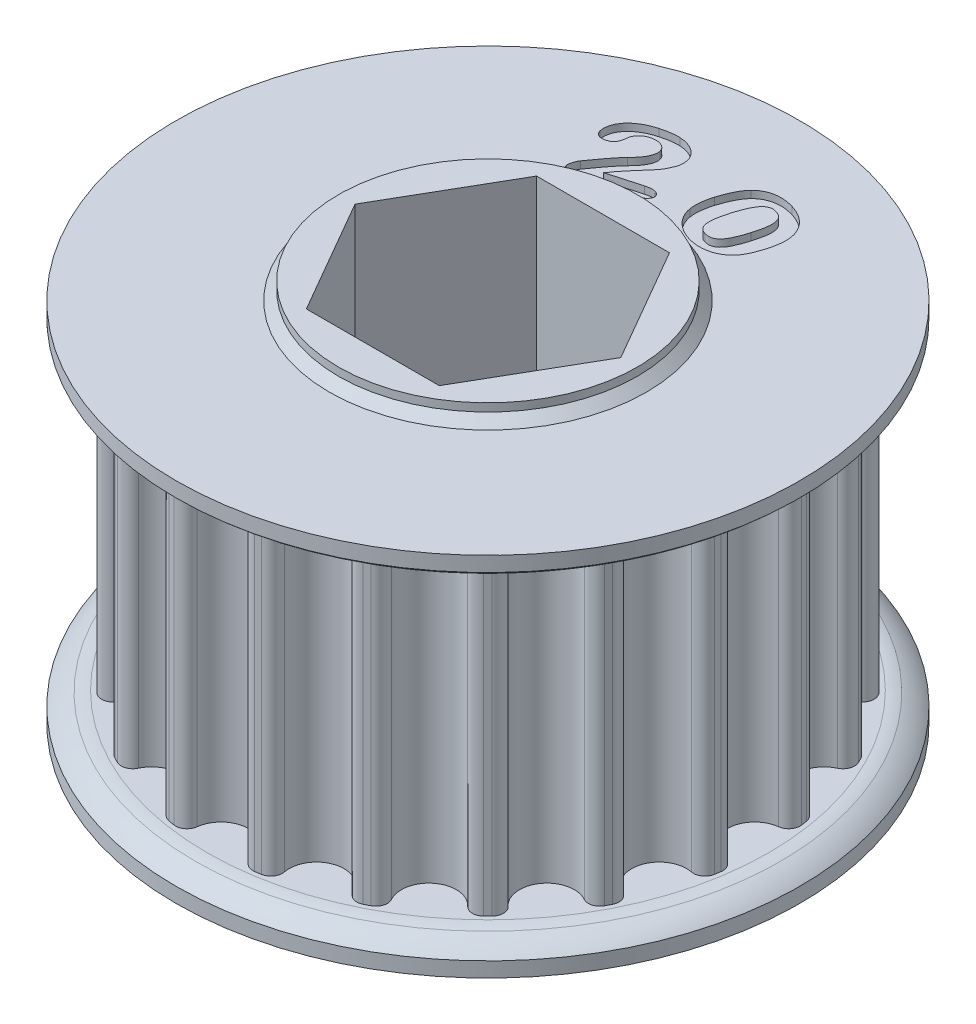
from build123d import *

# Parameters (mm, degrees)
SKETCH1_R               = 15.34399401
TOOTHOD_DEPTH           = 8.5725
TOOTHPROFILE_DEPTH      = 18.145
TOOTHPATTERN_COUNT      = 20
SKETCH6_W               = 8.2931
SKETCH6_H               = 0.9525
BORE_DEPTH              = 11.16
BORE_DEPTH_BACK         = 12.1125
LARGE_TOOTH_COUNT_DEPTH = 0.4
CHAMFER1_SIZE           = 0.508


with BuildPart() as part:
    # Sketch1 → ToothOD (new body, symmetric)
    with BuildSketch(Plane(origin=(0, 0, 0), x_dir=(1, 0, 0), z_dir=(0, 1, 0))):
        Circle(SKETCH1_R)
    extrude(amount=TOOTHOD_DEPTH, both=True)

    # Sketch2 → ToothProfile (cut, through all)
    with BuildSketch(Plane(origin=(0, 8.5725, 0), x_dir=(1, 0, 0), z_dir=(0, 1, 0))):
        with BuildLine():
            ThreePointArc((-1.514151189, 14.627414336), (0, 13.28399401), (1.514151189, 14.627414336))
            ThreePointArc((1.514151189, 14.627414336), (1.759047929, 15.056333772), (2.237219512, 15.180019797))
            ThreePointArc((2.237219512, 15.180019797), (0, 15.34399401), (-2.237219512, 15.180019797))
            ThreePointArc((-2.237219512, 15.180019797), (-1.759047929, 15.056333772), (-1.514151189, 14.627414336))
        make_face()
    toothprofile = extrude(amount=-TOOTHPROFILE_DEPTH, mode=Mode.SUBTRACT)

    # ToothPattern: ToothProfile ×20 about axis
    toothpattern_axis = Axis((0, 0, 0), (0, 1, 0))
    for i in range(1, TOOTHPATTERN_COUNT):
        add(toothprofile.rotate(toothpattern_axis, i * 360 / TOOTHPATTERN_COUNT), mode=Mode.SUBTRACT)

    # Sketch4 → Flange (revolve)
    with BuildSketch(Plane.XY):
        with BuildLine():
            Line((0, -8.5725), (15.59799401, -8.5725))
            ThreePointArc((15.59799401, -8.5725), (15.92375, -8.598122571), (16.243566338, -8.665137424))
            ThreePointArc((16.243566338, -8.665137424), (16.811294915, -8.946697125), (17.31249401, -9.3345))
            Line((17.31249401, -9.3345), (17.31249401, -10.16))
            Line((17.31249401, -10.16), (0, -10.16))
            Line((0, -10.16), (0, -8.5725))
        make_face()
        with BuildLine():
            Line((17.31249401, 10.16), (17.31249401, 9.3345))
            ThreePointArc((17.31249401, 9.3345), (16.811294915, 8.946697125), (16.243566338, 8.665137424))
            ThreePointArc((16.243566338, 8.665137424), (15.92375, 8.598122571), (15.59799401, 8.5725))
            Line((15.59799401, 8.5725), (0, 8.5725))
            Line((0, 8.5725), (0, 10.16))
            Line((0, 10.16), (17.31249401, 10.16))
        make_face()
    revolve(axis=Axis((0, 12.09802, 0), (0, -1, 0)))

    # Sketch6 → TopBearingBoss (revolve)
    with BuildSketch(Plane.XY):
        with Locations((4.14655, 10.63625)):
            Rectangle(SKETCH6_W, SKETCH6_H)
    revolve(axis=Axis((0, 12.09802, 0), (0, -1, 0)))

    # Sketch7 → Bore (cut, two sides)
    with BuildSketch(Plane.XZ) as bore_sk:
        Polygon((3.688171255, 6.3881), (-3.688171255, 6.3881), (-7.376342509, 0), (-3.688171255, -6.3881), (3.688171255, -6.3881), (7.376342509, 0), align=None)
    extrude(amount=BORE_DEPTH, mode=Mode.SUBTRACT)
    extrude(bore_sk.sketch, amount=-BORE_DEPTH_BACK, mode=Mode.SUBTRACT)

    # Sketch9 → Large Tooth Count (cut)
    with BuildSketch(Plane(origin=(0, 10.16, 0), x_dir=(1, 0, 0), z_dir=(0, 1, 0))):
        with BuildLine():
            Line((-2.954146893, 9.361462675), (-1.175353143, 9.862418144))
            add(Edge.make_bspline(
                [(-1.175353143, 9.862418144), (-1.123805554, 9.875802418), (-1.026048459, 9.901184938), (-0.883304523, 9.919166454), (-0.754108312, 9.920384436), (-0.63935479, 9.903206029), (-0.541555305, 9.870084112), (-0.462297286, 9.823371078), (-0.402653568, 9.761037925), (-0.383751751, 9.709454292), (-0.374360174, 9.683824394)],
                knots=[0, 0, 0, 0, 0.000159632, 0.000302733, 0.000430427, 0.000546114, 0.000649193, 0.000738172, 0.000820345, 0.000901492, 0.000901492, 0.000901492, 0.000901492], degree=3))
            add(Edge.make_bspline(
                [(-0.374360174, 9.683824394), (-0.369719108, 9.660087819), (-0.360266106, 9.611740771), (-0.371972129, 9.535402151), (-0.403229262, 9.458544917), (-0.453267189, 9.380882786), (-0.526096867, 9.307089619), (-0.62160342, 9.241903313), (-0.739824812, 9.186663473), (-0.827592685, 9.159151), (-0.874422674, 9.144471269)],
                knots=[0, 0, 0, 0, 7.211e-05, 0.000146874, 0.000227464, 0.000319855, 0.000422154, 0.000536349, 0.000664961, 0.000812085, 0.000812085, 0.000812085, 0.000812085], degree=3))
            Line((-0.874422674, 9.144471269), (-3.564937518, 8.387233769))
            add(Edge.make_bspline(
                [(-3.564937518, 8.387233769), (-3.61171521, 8.37543609), (-3.700837127, 8.352958886), (-3.832442975, 8.342282282), (-3.953746135, 8.349940914), (-4.062486177, 8.379695319), (-4.157127763, 8.424314562), (-4.233382296, 8.48426447), (-4.291165156, 8.557997927), (-4.311755017, 8.615372811), (-4.322175018, 8.644408769)],
                knots=[0, 0, 0, 0, 0.000144509, 0.000275322, 0.000394422, 0.00050728, 0.000611516, 0.000706209, 0.000796044, 0.00088809, 0.00088809, 0.00088809, 0.00088809], degree=3))
            add(Edge.make_bspline(
                [(-4.322175018, 8.644408769), (-4.326580812, 8.665164293), (-4.336073853, 8.709885638), (-4.332624611, 8.784411615), (-4.322455052, 8.869128107), (-4.299543845, 8.961161902), (-4.27034487, 9.054523865), (-4.235617728, 9.143365747), (-4.1961476, 9.224365129), (-4.163762464, 9.272780303), (-4.148046112, 9.296275956)],
                knots=[0, 0, 0, 0, 6.342e-05, 0.000136649, 0.000222155, 0.000319406, 0.000420513, 0.000515529, 0.000605383, 0.000690102, 0.000690102, 0.000690102, 0.000690102], degree=3))
            add(Edge.make_bspline(
                [(-4.148046112, 9.296275956), (-4.087211058, 9.382429832), (-3.969092279, 9.549708234), (-3.794337723, 9.790740454), (-3.627134069, 10.014150132), (-3.493100044, 10.188605296), (-3.391151145, 10.317214682), (-3.321382624, 10.403735091), (-3.257675155, 10.482773388), (-3.197071967, 10.55186435), (-3.144281079, 10.614722485), (-3.095438484, 10.668632161), (-3.052483765, 10.714698958), (-3.024770261, 10.742069301), (-3.012189862, 10.754493925)],
                knots=[0, 0, 0, 0, 0.000316401, 0.000614331, 0.000893117, 0.001153528, 0.0012743, 0.001385449, 0.001486981, 0.0015788, 0.001661128, 0.00173321, 0.001797012, 0.001850052, 0.001850052, 0.001850052, 0.001850052], degree=3))
            add(Edge.make_bspline(
                [(-3.012189862, 10.754493925), (-2.97279762, 10.794299168), (-2.896763622, 10.871130331), (-2.792806568, 10.988869332), (-2.701039663, 11.102694717), (-2.620574498, 11.212717556), (-2.553383732, 11.320286413), (-2.497592916, 11.424476859), (-2.454002898, 11.526306534), (-2.422746917, 11.625053273), (-2.402709489, 11.71988848), (-2.394004008, 11.810101015), (-2.397937406, 11.895345873), (-2.409888983, 11.949103964), (-2.415686737, 11.975182206)],
                knots=[0, 0, 0, 0, 0.000167978, 0.000324227, 0.000470938, 0.00060651, 0.000732874, 0.000851114, 0.000960746, 0.001064676, 0.001161348, 0.001251006, 0.001335955, 0.001415989, 0.001415989, 0.001415989, 0.001415989], degree=3))
            add(Edge.make_bspline(
                [(-2.415686737, 11.975182206), (-2.42429087, 12.001758675), (-2.441249197, 12.0541396), (-2.482578582, 12.125664714), (-2.535327991, 12.18909487), (-2.598872825, 12.244238856), (-2.671873029, 12.2906639), (-2.752660218, 12.328719573), (-2.842148698, 12.355153399), (-2.938047159, 12.37159083), (-3.038305704, 12.378979246), (-3.141121707, 12.374657925), (-3.245814936, 12.36229657), (-3.314774119, 12.344214881), (-3.349732049, 12.335048613)],
                knots=[0, 0, 0, 0, 8.3615e-05, 0.000164802, 0.000245979, 0.00033015, 0.000416103, 0.00050479, 0.000597164, 0.000695086, 0.000796244, 0.000898105, 0.001003437, 0.001111733, 0.001111733, 0.001111733, 0.001111733], degree=3))
            add(Edge.make_bspline(
                [(-3.349732049, 12.335048613), (-3.382418939, 12.324700344), (-3.446620887, 12.304374794), (-3.537125411, 12.263067652), (-3.620087769, 12.213267396), (-3.696565155, 12.156329349), (-3.765107736, 12.089722279), (-3.824340499, 12.013694183), (-3.879435722, 11.931578737), (-3.907718253, 11.87113381), (-3.922125018, 11.840343925)],
                knots=[0, 0, 0, 0, 0.000102788, 0.000201892, 0.000297606, 0.000392618, 0.00048734, 0.000583288, 0.000681368, 0.000783202, 0.000783202, 0.000783202, 0.000783202], degree=3))
            add(Edge.make_bspline(
                [(-3.922125018, 11.840343925), (-3.924346544, 11.832933466), (-3.931168204, 11.810178107), (-3.937056605, 11.762522536), (-3.950091222, 11.690823835), (-3.961933852, 11.598900745), (-3.979992527, 11.497578612), (-4.007626887, 11.398655278), (-4.042740729, 11.30637416), (-4.085519388, 11.220216479), (-4.144929258, 11.141703059), (-4.227777014, 11.077150199), (-4.330942518, 11.022005189), (-4.409730011, 10.997774061), (-4.451655487, 10.984879863)],
                knots=[0, 0, 0, 0, 2.3183e-05, 7.1188e-05, 0.000143562, 0.000241939, 0.000349125, 0.000452037, 0.000549551, 0.000645003, 0.000739847, 0.000842071, 0.000957527, 0.001088842, 0.001088842, 0.001088842, 0.001088842], degree=3))
            add(Edge.make_bspline(
                [(-4.451655487, 10.984879863), (-4.484518593, 10.977014405), (-4.548160913, 10.961782248), (-4.644496368, 10.956258535), (-4.73670461, 10.966954595), (-4.82346759, 10.993238394), (-4.901057808, 11.035922061), (-4.965744414, 11.095093645), (-5.016154224, 11.169717324), (-5.035502925, 11.227460955), (-5.045479705, 11.257235331)],
                knots=[0, 0, 0, 0, 0.000101225, 0.000196031, 0.000287742, 0.000378408, 0.000466355, 0.000551051, 0.00063922, 0.00073308, 0.00073308, 0.00073308, 0.00073308], degree=3))
            add(Edge.make_bspline(
                [(-5.045479705, 11.257235331), (-5.05397104, 11.293084372), (-5.071349422, 11.366453082), (-5.077754738, 11.481958813), (-5.072725552, 11.603249079), (-5.051844202, 11.729081667), (-5.016292017, 11.857336166), (-4.964770167, 11.985211731), (-4.897422878, 12.111016582), (-4.814660026, 12.23509846), (-4.715205717, 12.356092866), (-4.597286749, 12.47195975), (-4.46284857, 12.584034957), (-4.31031455, 12.689978389), (-4.14049305, 12.79094259), (-3.950695814, 12.87981994), (-3.743341884, 12.961365981), (-3.596866185, 13.004705712), (-3.521182049, 13.027099394)],
                knots=[0, 0, 0, 0, 0.000110331, 0.000225804, 0.000345582, 0.000474036, 0.000607492, 0.000744128, 0.000886741, 0.001034844, 0.001190912, 0.001355715, 0.001530073, 0.001715374, 0.001912322, 0.002122017, 0.002343396, 0.002580075, 0.002580075, 0.002580075, 0.002580075], degree=3))
            add(Edge.make_bspline(
                [(-3.521182049, 13.027099394), (-3.4736299, 13.03988753), (-3.380335158, 13.064977161), (-3.241544955, 13.097089226), (-3.107026771, 13.124112364), (-2.976265984, 13.14490228), (-2.8495897, 13.158917372), (-2.727192142, 13.168269746), (-2.608850533, 13.171070654), (-2.531470246, 13.16854091), (-2.493375018, 13.167295488)],
                knots=[0, 0, 0, 0, 0.000147715, 0.00028981, 0.000427283, 0.000559265, 0.000686869, 0.000809531, 0.000927433, 0.001041765, 0.001041765, 0.001041765, 0.001041765], degree=3))
            add(Edge.make_bspline(
                [(-2.493375018, 13.167295488), (-2.439709954, 13.16272022), (-2.334541326, 13.153753966), (-2.181332224, 13.127305431), (-2.036981563, 13.087440761), (-1.901006644, 13.037993111), (-1.775042238, 12.977076771), (-1.658865503, 12.907098719), (-1.552797444, 12.827923999), (-1.459758972, 12.738048259), (-1.376703421, 12.643511102), (-1.309975797, 12.541360057), (-1.254518112, 12.43604159), (-1.230849347, 12.361372234), (-1.219108612, 12.324332988)],
                knots=[0, 0, 0, 0, 0.000161536, 0.000316566, 0.000465606, 0.000610256, 0.000750042, 0.000884655, 0.001016637, 0.001146117, 0.001272127, 0.001393235, 0.001511445, 0.001627798, 0.001627798, 0.001627798, 0.001627798], degree=3))
            add(Edge.make_bspline(
                [(-1.219108612, 12.324332988), (-1.211383801, 12.294688493), (-1.195989155, 12.235610479), (-1.183332882, 12.145192252), (-1.176603551, 12.054774787), (-1.178486449, 11.963899215), (-1.188610174, 11.872881101), (-1.205430531, 11.781423706), (-1.230525716, 11.690002431), (-1.274849659, 11.570781829), (-1.33741533, 11.429640428), (-1.41591175, 11.271086939), (-1.50151055, 11.130952631), (-1.579521706, 11.024672795), (-1.647287016, 10.941396881), (-1.706925628, 10.872235184), (-1.772228142, 10.792201909), (-1.847731998, 10.704799598), (-1.931711291, 10.608913676), (-2.022333861, 10.502919779), (-2.123153923, 10.389883416), (-2.227945717, 10.269423426), (-2.334199707, 10.149850826), (-2.432223405, 10.033064938), (-2.522427016, 9.924904713), (-2.603216232, 9.823238211), (-2.675411176, 9.729477266), (-2.73794607, 9.642126083), (-2.79312732, 9.563443557), (-2.824329241, 9.511648282), (-2.838953924, 9.487371269)],
                knots=[0, 0, 0, 0, 9.1833e-05, 0.000183012, 0.000273418, 0.000363625, 0.000455236, 0.000547886, 0.000642338, 0.000739228, 0.000929181, 0.001105295, 0.001269623, 0.001421084, 0.001500437, 0.001591678, 0.001695035, 0.001810293, 0.001938147, 0.002077427, 0.002228635, 0.002392525, 0.002556416, 0.002708483, 0.002849914, 0.002978913, 0.00309804, 0.003204857, 0.003301207, 0.003386208, 0.003386208, 0.003386208, 0.003386208], degree=3))
            add(Edge.make_bspline(
                [(-2.838953924, 9.487371269), (-2.855289837, 9.463900755), (-2.888073876, 9.416798504), (-2.932072354, 9.379949994), (-2.954146893, 9.361462675)],
                knots=[0, 0, 0, 0, 8.5371e-05, 0.000171328, 0.000171328, 0.000171328, 0.000171328], degree=3))
        make_face()
        with BuildLine():
            add(Edge.make_bspline(
                [(5.214409045, 10.150130338), (5.190714867, 10.074880459), (5.1449507, 9.929538937), (5.067123561, 9.722992573), (4.985074358, 9.534662094), (4.897683151, 9.362490125), (4.797990216, 9.204699763), (4.68207819, 9.059315083), (4.548391417, 8.924355594), (4.448207144, 8.844811647), (4.397342639, 8.804426432)],
                knots=[0, 0, 0, 0, 0.000236642, 0.000457062, 0.000661792, 0.000852695, 0.001035762, 0.001220684, 0.001409481, 0.001604192, 0.001604192, 0.001604192, 0.001604192], degree=3))
            add(Edge.make_bspline(
                [(4.397342639, 8.804426432), (4.368452389, 8.783759012), (4.310444351, 8.742261398), (4.218090567, 8.68760354), (4.122567032, 8.636381907), (4.021053968, 8.594804769), (3.917071626, 8.55542857), (3.807864453, 8.524522636), (3.694856927, 8.498897601), (3.578149786, 8.477916033), (3.458784674, 8.465052918), (3.337809148, 8.457659325), (3.215789514, 8.457269131), (3.092816601, 8.466425015), (2.968336345, 8.478893397), (2.842901635, 8.500737733), (2.716334551, 8.529457806), (2.632441476, 8.553128463), (2.589973889, 8.565110807)],
                knots=[0, 0, 0, 0, 0.000106514, 0.000213868, 0.00032171, 0.000431342, 0.000542652, 0.00065513, 0.000771456, 0.000890225, 0.00101063, 0.001131392, 0.001253729, 0.001376329, 0.001501172, 0.001628892, 0.001758002, 0.001890361, 0.001890361, 0.001890361, 0.001890361], degree=3))
            add(Edge.make_bspline(
                [(2.589973889, 8.565110807), (2.543632445, 8.579700214), (2.452042396, 8.608534977), (2.319678008, 8.661606647), (2.193694452, 8.721556974), (2.07328836, 8.787716416), (1.959122861, 8.861323411), (1.84975651, 8.940228266), (1.747631416, 9.027720056), (1.651608943, 9.121077228), (1.562444683, 9.219388851), (1.482907007, 9.322900319), (1.410803045, 9.429205404), (1.348352462, 9.54012966), (1.294619283, 9.655154495), (1.248761777, 9.773672505), (1.213020235, 9.896616587), (1.195786369, 9.980335913), (1.187119983, 10.022435807)],
                knots=[0, 0, 0, 0, 0.00014571, 0.000287984, 0.000427384, 0.000564075, 0.000699818, 0.000834669, 0.000968331, 0.001102838, 0.001236249, 0.001366101, 0.001494145, 0.001621298, 0.001747533, 0.00187473, 0.002002174, 0.00213109, 0.00213109, 0.00213109, 0.00213109], degree=3))
            add(Edge.make_bspline(
                [(1.187119983, 10.022435807), (1.180867164, 10.069996862), (1.168240345, 10.166040708), (1.1601745, 10.312869392), (1.163621366, 10.463459377), (1.174789304, 10.6179706), (1.197160825, 10.776345136), (1.22609065, 10.938288092), (1.264806684, 11.103647427), (1.296751927, 11.213792398), (1.313028577, 11.26991315)],
                knots=[0, 0, 0, 0, 0.000143879, 0.000290546, 0.000440589, 0.000595508, 0.00075501, 0.00092018, 0.001088913, 0.001264195, 0.001264195, 0.001264195, 0.001264195], degree=3))
            add(Edge.make_bspline(
                [(1.313028577, 11.26991315), (1.33538935, 11.341535758), (1.379078841, 11.481475247), (1.452154195, 11.682542865), (1.529127683, 11.87032368), (1.609998022, 12.044290335), (1.6952769, 12.205137541), (1.787378592, 12.350429447), (1.883615047, 12.482465752), (1.954403412, 12.561103972), (1.98900592, 12.599543619)],
                knots=[0, 0, 0, 0, 0.000225072, 0.000439757, 0.00064157, 0.000833726, 0.001015104, 0.001187283, 0.001349449, 0.00150452, 0.00150452, 0.00150452, 0.00150452], degree=3))
            add(Edge.make_bspline(
                [(1.98900592, 12.599543619), (2.018628391, 12.628603845), (2.077103584, 12.685969161), (2.171791495, 12.762895464), (2.270271079, 12.832357217), (2.373785475, 12.892330016), (2.480624357, 12.946184702), (2.592696711, 12.989493011), (2.708793143, 13.025239338), (2.829056329, 13.052964555), (2.952560802, 13.072627552), (3.079412612, 13.083143097), (3.208835866, 13.085694737), (3.341290865, 13.080548732), (3.476299628, 13.065774952), (3.61437117, 13.043471927), (3.75507657, 13.012338384), (3.848891552, 12.985499356), (3.89638717, 12.971911588)],
                knots=[0, 0, 0, 0, 0.000124431, 0.000245628, 0.000365529, 0.000485599, 0.000604206, 0.000724097, 0.000845554, 0.000968372, 0.001094039, 0.001220403, 0.001349911, 0.001482179, 0.001617772, 0.00175709, 0.001901599, 0.002049778, 0.002049778, 0.002049778, 0.002049778], degree=3))
            add(Edge.make_bspline(
                [(3.89638717, 12.971911588), (3.961047138, 12.951501287), (4.087573261, 12.911562568), (4.26784755, 12.835416509), (4.436188729, 12.750440953), (4.590932452, 12.653297499), (4.733128735, 12.548330058), (4.861794309, 12.434592971), (4.975915242, 12.311534463), (5.075655196, 12.180079229), (5.162485109, 12.042696768), (5.235003627, 11.900099386), (5.294184558, 11.753211843), (5.321379679, 11.651830378), (5.334959827, 11.601204557)],
                knots=[0, 0, 0, 0, 0.000203315, 0.000397845, 0.000586344, 0.000768459, 0.000945269, 0.001116052, 0.001282868, 0.001447893, 0.001610416, 0.00176976, 0.00192729, 0.002084417, 0.002084417, 0.002084417, 0.002084417], degree=3))
            add(Edge.make_bspline(
                [(5.334959827, 11.601204557), (5.345438057, 11.551051125), (5.366875769, 11.448440786), (5.381402987, 11.288093713), (5.386496657, 11.119523422), (5.37668279, 10.94229087), (5.355085027, 10.756243659), (5.320633311, 10.561374709), (5.274470628, 10.357721475), (5.234765054, 10.220486907), (5.214409045, 10.150130338)],
                knots=[0, 0, 0, 0, 0.000153593, 0.000314241, 0.000482178, 0.000659211, 0.000846181, 0.001043784, 0.001252609, 0.001472295, 0.001472295, 0.001472295, 0.001472295], degree=3))
        make_face()
        with BuildLine():
            add(Edge.make_bspline(
                [(4.031225452, 10.56982565), (4.04357031, 10.611754452), (4.067764283, 10.693928279), (4.100757692, 10.814739321), (4.129381589, 10.930615781), (4.154607751, 11.040966004), (4.17517115, 11.146384723), (4.191469661, 11.246428339), (4.20286392, 11.341205651), (4.213841097, 11.457443534), (4.216752136, 11.592054856), (4.202110036, 11.740591906), (4.171074433, 11.872605872), (4.127424694, 11.969388232), (4.083881673, 12.037912926), (4.045434796, 12.084373108), (4.000776302, 12.126406709), (3.951930174, 12.1663729), (3.895704752, 12.200546592), (3.835309816, 12.2331379), (3.768732382, 12.260690902), (3.722073138, 12.275724197), (3.698148108, 12.283432682)],
                knots=[0, 0, 0, 0, 0.000131124, 0.000256981, 0.000375666, 0.000489182, 0.000596535, 0.000697831, 0.000793195, 0.000882853, 0.001048073, 0.001196193, 0.001329605, 0.001453096, 0.001512544, 0.001572798, 0.001633428, 0.001696323, 0.00176173, 0.001830436, 0.00190208, 0.001977477, 0.001977477, 0.001977477, 0.001977477], degree=3))
            add(Edge.make_bspline(
                [(3.698148108, 12.283432682), (3.667653286, 12.291427612), (3.608467335, 12.306944593), (3.518859453, 12.315603473), (3.43228089, 12.313007472), (3.348970179, 12.294162773), (3.268843326, 12.263717987), (3.191916068, 12.219918135), (3.118272519, 12.163156193), (3.048551775, 12.092068958), (2.979738045, 12.008223912), (2.914539397, 11.907932136), (2.848206908, 11.793856803), (2.784246551, 11.663475333), (2.721164908, 11.517923561), (2.658918626, 11.35696549), (2.597074002, 11.180720122), (2.558899013, 11.057224397), (2.53907467, 10.993092838)],
                knots=[0, 0, 0, 0, 9.444e-05, 0.000183293, 0.000269093, 0.000353165, 0.000438241, 0.000525409, 0.000617749, 0.000716251, 0.0008235, 0.000942627, 0.001074653, 0.001219218, 0.001377981, 0.001550441, 0.001736835, 0.001938197, 0.001938197, 0.001938197, 0.001938197], degree=3))
            add(Edge.make_bspline(
                [(2.53907467, 10.993092838), (2.525780531, 10.948798919), (2.499803053, 10.862246169), (2.465057265, 10.73449515), (2.434565149, 10.612447484), (2.409051423, 10.496192633), (2.385689628, 10.386027538), (2.369510135, 10.280960181), (2.355595424, 10.18190809), (2.343868918, 10.061130514), (2.339639419, 9.922828249), (2.350968028, 9.771566451), (2.3796989, 9.639943096), (2.426133084, 9.526879767), (2.492105714, 9.432454634), (2.5754877, 9.355240728), (2.675763288, 9.292853541), (2.751545994, 9.266420565), (2.790891858, 9.252696744)],
                knots=[0, 0, 0, 0, 0.000138732, 0.000271091, 0.000397139, 0.000516078, 0.000628159, 0.000734886, 0.000834907, 0.000928204, 0.001098819, 0.001249358, 0.001382149, 0.001501397, 0.001613616, 0.001724812, 0.001840291, 0.001964991, 0.001964991, 0.001964991, 0.001964991], degree=3))
            add(Edge.make_bspline(
                [(2.790891858, 9.252696744), (2.81520806, 9.24606045), (2.862572058, 9.233134031), (2.933678635, 9.220591584), (3.00207604, 9.214307045), (3.068211057, 9.213853312), (3.131658175, 9.221202469), (3.192706609, 9.234608636), (3.251390292, 9.254092676), (3.326480383, 9.29123363), (3.417640784, 9.352659395), (3.517714155, 9.450500325), (3.613187275, 9.570539223), (3.684054974, 9.688732373), (3.739933925, 9.794808606), (3.782672042, 9.883814369), (3.824376633, 9.980554467), (3.866377238, 10.084159167), (3.908185032, 10.194975421), (3.950511202, 10.312951239), (3.99116818, 10.438835364), (4.017651783, 10.525438733), (4.031225452, 10.56982565)],
                knots=[0, 0, 0, 0, 7.5587e-05, 0.00014723, 0.000216272, 0.000281459, 0.000345261, 0.000407443, 0.00046872, 0.000530225, 0.000658269, 0.000796587, 0.000948457, 0.00111723, 0.001209102, 0.001308153, 0.00141333, 0.001525094, 0.001643509, 0.00176863, 0.00190107, 0.002040319, 0.002040319, 0.002040319, 0.002040319], degree=3))
        make_face(mode=Mode.SUBTRACT)
    extrude(amount=-LARGE_TOOTH_COUNT_DEPTH, mode=Mode.SUBTRACT)

    # Chamfer1
    chamfer1_edges = [part.edges().sort_by_distance(p)[0] for p in [
        (-8.2931, 10.16, 0),
    ]]
    chamfer(chamfer1_edges, length=CHAMFER1_SIZE)


solid = part.part
